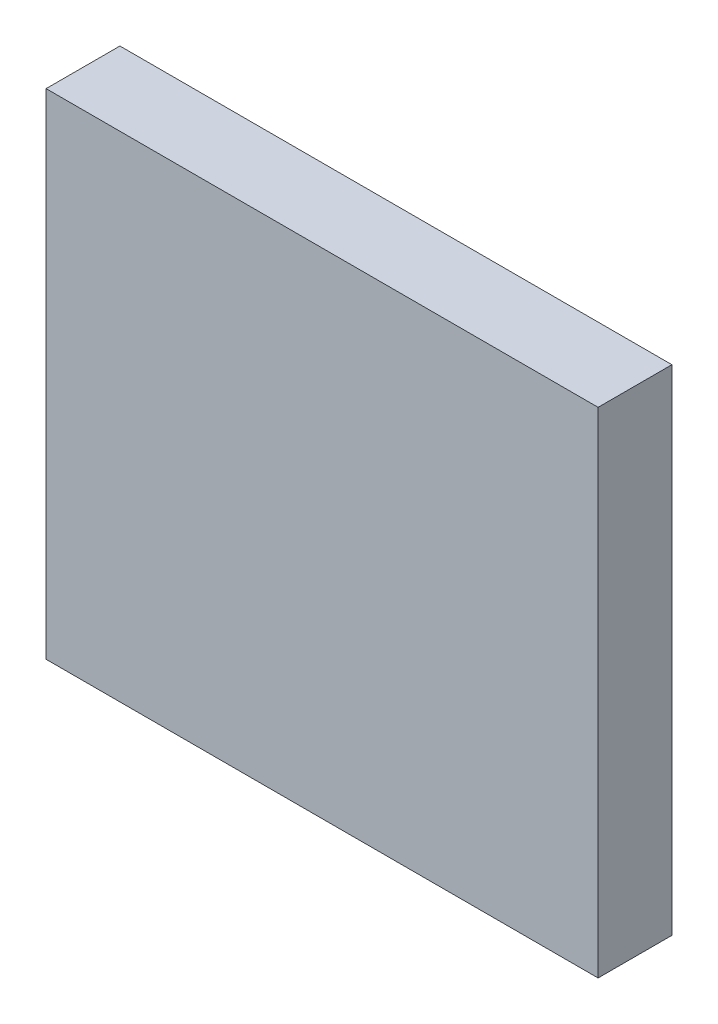
from build123d import *

# Parameters (mm, degrees)
SKETCH_1_W      = 17.2
SKETCH_1_H      = 15.4
EXTRUDE_1_DEPTH = 2.3


with BuildPart() as part:
    # Эскиз1 → Бобышка-Вытянуть1 (new body)
    with BuildSketch(Plane.XY):
        Rectangle(SKETCH_1_W, SKETCH_1_H)
    extrude(amount=EXTRUDE_1_DEPTH)


solid = part.part
